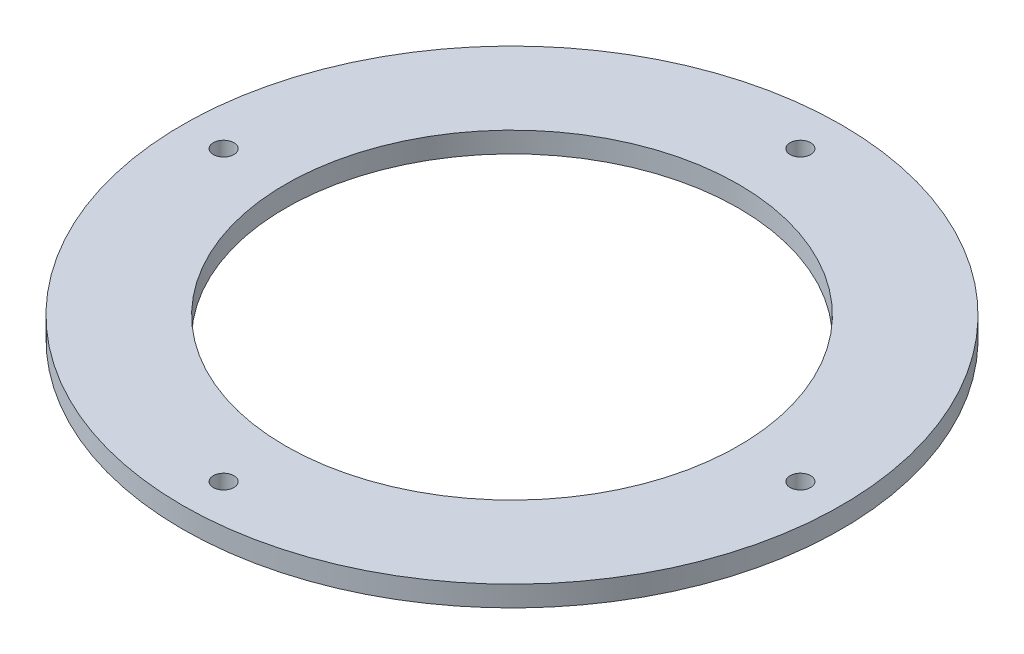
from build123d import *

# Parameters (mm, degrees)
SKETCH1_R           = 101.6
SKETCH1_R_2         = 69.85
BOSS_EXTRUDE1_DEPTH = 6.35
SKETCH2_R           = 3.175
CUT_EXTRUDE1_DEPTH  = 6.35


with BuildPart() as part:
    # Sketch1 → Boss-Extrude1 (new body)
    with BuildSketch(Plane(origin=(0, 0, 0), x_dir=(1, 0, 0), z_dir=(0, 1, 0))):
        with Locations(Location((0, 0, 0), (0, 0, 270))):  # turned: the seam where the file's is
            Circle(SKETCH1_R)
        with Locations(Location((0, 0, 0), (0, 0, 270))):  # turned: the seam where the file's is
            Circle(SKETCH1_R_2, mode=Mode.SUBTRACT)
    extrude(amount=BOSS_EXTRUDE1_DEPTH)

    # Sketch2 → Cut-Extrude1 (cut)
    with BuildSketch(Plane(origin=(0, 6.35, 0), x_dir=(1, 0, 0), z_dir=(0, 1, 0))):
        with Locations(Location((0, 88.9, 0), (0, 0, 270))):  # turned: the seam where the file's is
            Circle(SKETCH2_R)
        with Locations(Location((88.9, 0, 0), (0, 0, 270))):  # turned: the seam where the file's is
            Circle(SKETCH2_R)
        with Locations(Location((0, -88.9, 0), (0, 0, 270))):  # turned: the seam where the file's is
            Circle(SKETCH2_R)
        with Locations(Location((-88.9, 0, 0), (0, 0, 270))):  # turned: the seam where the file's is
            Circle(SKETCH2_R)
    extrude(amount=-CUT_EXTRUDE1_DEPTH, mode=Mode.SUBTRACT)


solid = part.part
